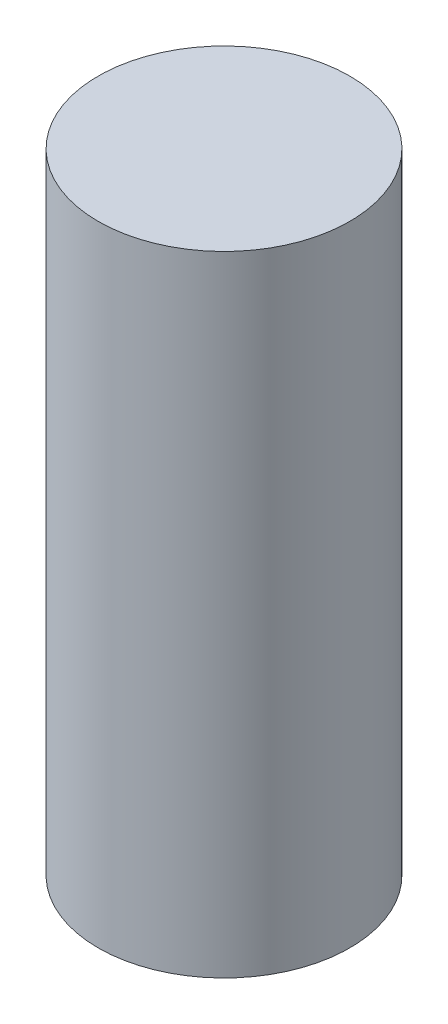
from build123d import *

# Parameters (mm, degrees)
SKETCH1_R           = 3.175
BOSS_EXTRUDE1_DEPTH = 15.875


with BuildPart() as part:
    # Sketch1 → Boss-Extrude1 (new body)
    with BuildSketch(Plane(origin=(0, 0, 0), x_dir=(1, 0, 0), z_dir=(0, 1, 0))):
        Circle(SKETCH1_R)
    extrude(amount=BOSS_EXTRUDE1_DEPTH)


solid = part.part
